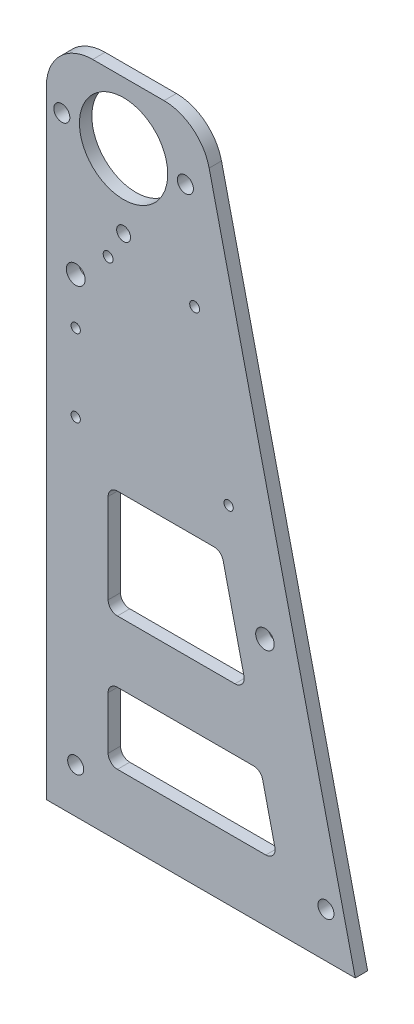
from build123d import *

# Parameters (mm, degrees)
ESBO_O1_R                = 14.2875
ESBO_O1_R_2              = 2.6
RESSALTO_EXTRUS_O2_DEPTH = 4
FILETE1_R                = 15
ESBO_O3_R                = 1.5
ESBO_O3_R_2              = 2.6
ESBO_O3_R_3              = 3.05
CORTE_EXTRUS_O1_DEPTH    = 5
ESBO_O5_R                = 2.25
ESBO_O5_R_2              = 3
ESBO_O5_R_3              = 1.6
ESBO_O5_R_4              = 2.6
CORTE_EXTRUS_O2_DEPTH    = 5


with BuildPart() as part:
    # Esboço1 → Ressalto-extrusão2 (new body)
    with BuildSketch(Plane.XY):
        Polygon((0, 0), (0, 215), (50, 215), (100, 0), align=None)
        with Locations((25, 195)):
            Circle(ESBO_O1_R, mode=Mode.SUBTRACT)
        with Locations((9.5, 14.5)):
            Circle(ESBO_O1_R_2, mode=Mode.SUBTRACT)
        with BuildLine():
            Line((20, 95), (20, 66))
            ThreePointArc((20, 66), (20.878679656, 63.878679656), (23, 63))
            Line((23, 63), (61.03739436, 63))
            ThreePointArc((61.03739436, 63), (63.386715693, 64.134339454), (63.959418441, 66.679540484))
            Line((63.959418441, 66.679540484), (57.215232395, 95.679540484))
            ThreePointArc((57.215232395, 95.679540484), (56.15886886, 97.349321333), (54.293208314, 98))
            Line((54.293208314, 98), (23, 98))
            ThreePointArc((23, 98), (20.878679656, 97.121320344), (20, 95))
        make_face(mode=Mode.SUBTRACT)
        with BuildLine():
            Line((20, 40), (20, 23))
            ThreePointArc((20, 23), (20.878679656, 20.878679656), (23, 20))
            Line((23, 20), (71.03739436, 20))
            ThreePointArc((71.03739436, 20), (73.386715693, 21.134339454), (73.959418441, 23.679540484))
            Line((73.959418441, 23.679540484), (70.005930069, 40.679540484))
            ThreePointArc((70.005930069, 40.679540484), (68.949566534, 42.349321333), (67.083905988, 43))
            Line((67.083905988, 43), (23, 43))
            ThreePointArc((23, 43), (20.878679656, 42.121320344), (20, 40))
        make_face(mode=Mode.SUBTRACT)
    extrude(amount=RESSALTO_EXTRUS_O2_DEPTH)

    # Filete1
    filete1_edges = [part.edges().sort_by_distance(p)[0] for p in [
        (0, 215, 2),
        (50, 215, 2),
    ]]
    fillet(filete1_edges, radius=FILETE1_R)

    # Esboço3 → Corte-extrusão1 (cut, through all)
    with BuildSketch(Plane(origin=(0, 0, 0), x_dir=(-1, 0, 0), z_dir=(0, 0, -1))):
        with Locations((-9.5, 112)):
            Circle(ESBO_O3_R)
        with Locations((-90.5, 14.5)):
            Circle(ESBO_O3_R_2)
        with Locations((-9.5, 137)):
            Circle(ESBO_O3_R)
        with Locations((-9.5, 152)):
            Circle(ESBO_O3_R_3)
        with Locations((-59, 112)):
            Circle(ESBO_O3_R)
    extrude(amount=-CORTE_EXTRUS_O1_DEPTH, mode=Mode.SUBTRACT)

    # Esboço5 → Corte-extrusão2 (cut, through all)
    with BuildSketch(Plane(origin=(0, 0, 0), x_dir=(-1, 0, 0), z_dir=(0, 0, -1))):
        with Locations((-25, 171.1875)):
            Circle(ESBO_O5_R)
        with Locations((-70.759810426, 80.398555206)):
            Circle(ESBO_O5_R_2)
        with Locations((-20, 162.1875)):
            Circle(ESBO_O5_R_3)
        with Locations((-48, 162.1875)):
            Circle(ESBO_O5_R_3)
        with Locations((-45, 195)):
            Circle(ESBO_O5_R_4)
        with Locations((-5, 195)):
            Circle(ESBO_O5_R_4)
    extrude(amount=-CORTE_EXTRUS_O2_DEPTH, mode=Mode.SUBTRACT)


solid = part.part
